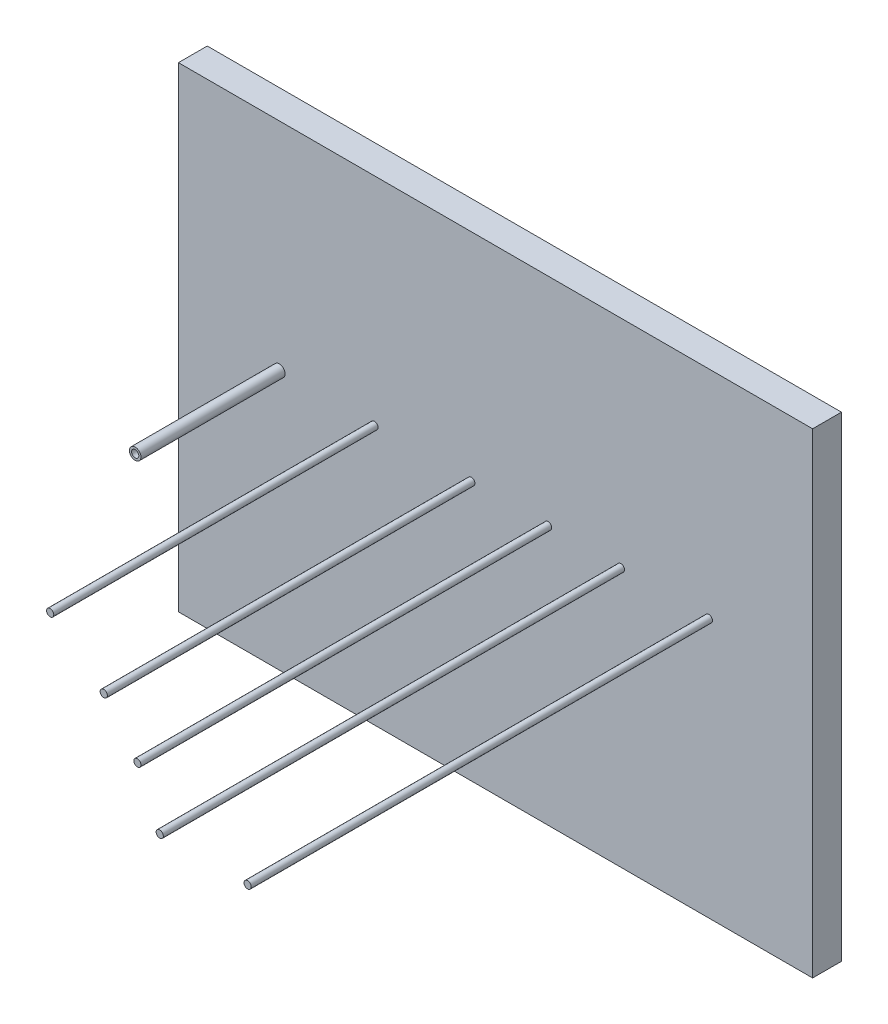
from build123d import *

# Parameters (mm, degrees)
CROQUIS1_W              = 440
CROQUIS1_H              = 330
SALIENTE_EXTRUIR1_DEPTH = 20
CROQUIS3_R              = 4
SALIENTE_EXTRUIR2_DEPTH = 100
CROQUIS5_R              = 2.5
CORTAR_EXTRUIR2_DEPTH   = 100
CROQUIS3_3_R            = 2.5
SALIENTE_EXTRUIR3_DEPTH = 225
CROQUIS3_4_R            = 2.5
SALIENTE_EXTRUIR4_DEPTH = 255
CROQUIS3_5_R            = 2.5
SALIENTE_EXTRUIR5_DEPTH = 255
CROQUIS3_6_R            = 2.5
SALIENTE_EXTRUIR6_DEPTH = 285
CROQUIS3_7_R            = 2.5
SALIENTE_EXTRUIR7_DEPTH = 320


with BuildPart() as part:
    # Croquis1 → Saliente-Extruir1 (new body)
    with BuildSketch(Plane.XY):
        with Locations((220, 165)):
            Rectangle(CROQUIS1_W, CROQUIS1_H)
    extrude(amount=SALIENTE_EXTRUIR1_DEPTH)

    # Croquis3 → Saliente-Extruir2 (add)
    with BuildSketch(Plane.XY.offset(20)):
        with Locations((70, 180)):
            Circle(CROQUIS3_R)
    extrude(amount=SALIENTE_EXTRUIR2_DEPTH)

    # Croquis5 → Cortar-Extruir2 (cut)
    with BuildSketch(Plane.XY.offset(120)):
        with Locations((70, 180)):
            Circle(CROQUIS5_R)
    extrude(amount=-CORTAR_EXTRUIR2_DEPTH, mode=Mode.SUBTRACT)

    # Croquis3_3 → Saliente-Extruir3 (add)
    with BuildSketch(Plane.XY.offset(20)):
        with Locations((136, 180)):
            Circle(CROQUIS3_3_R)
    extrude(amount=SALIENTE_EXTRUIR3_DEPTH)

    # Croquis3_4 → Saliente-Extruir4 (add)
    with BuildSketch(Plane.XY.offset(20)):
        with Locations((203.2, 180)):
            Circle(CROQUIS3_4_R)
    extrude(amount=SALIENTE_EXTRUIR4_DEPTH)

    # Croquis3_5 → Saliente-Extruir5 (add)
    with BuildSketch(Plane.XY.offset(20)):
        with Locations((203.2, 180)):
            Circle(CROQUIS3_5_R)
    extrude(amount=SALIENTE_EXTRUIR5_DEPTH)

    # Croquis3_6 → Saliente-Extruir6 (add)
    with BuildSketch(Plane.XY.offset(20)):
        with Locations((256.5, 180)):
            Circle(CROQUIS3_6_R)
    extrude(amount=SALIENTE_EXTRUIR6_DEPTH)

    # Croquis3_7 → Saliente-Extruir7 (add)
    with BuildSketch(Plane.XY.offset(20)):
        with Locations((307, 180)):
            Circle(CROQUIS3_7_R)
        with Locations((368, 180)):
            Circle(CROQUIS3_7_R)
    extrude(amount=SALIENTE_EXTRUIR7_DEPTH)


solid = part.part
